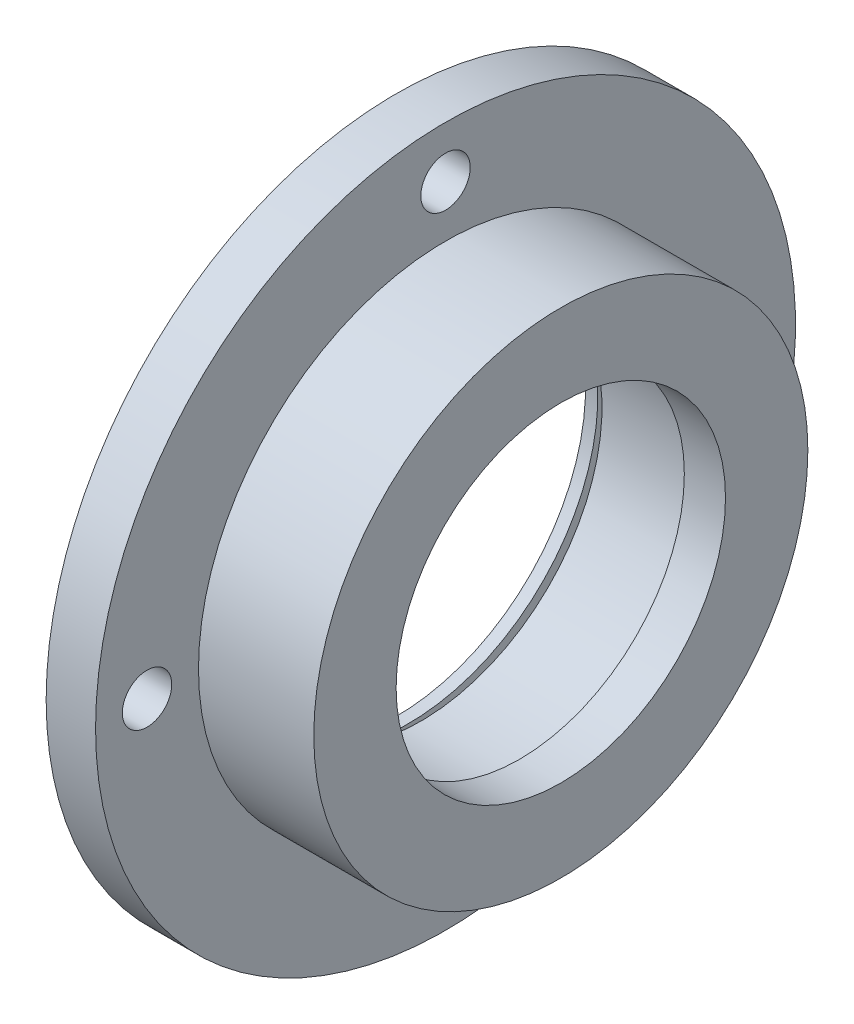
from build123d import *

# Parameters (mm, degrees)
ESBO_O2_R             = 3
CORTE_EXTRUS_O1_DEPTH = 7


with BuildPart() as part:
    # Esboço1 → Revolução1 (revolve)
    with BuildSketch(Plane.XY):
        Polygon((0, 23), (0, 42.5), (6, 42.5), (6, 30), (20, 30), (20, 20), (15, 20), (15, 22), (3, 22), (3, 24.5), (1.5, 24.5), (1.5, 23), align=None)
    revolve(axis=Axis((0, 0, 0), (1, 0, 0)))

    # Esboço2 → Corte-extrusão1 (cut, through all)
    with BuildSketch(Plane(origin=(6, 0, 0), x_dir=(0, 0, -1), z_dir=(1, 0, 0))):
        with Locations((0, 36.25)):
            Circle(ESBO_O2_R)
        with Locations((36.25, 0)):
            Circle(ESBO_O2_R)
        with Locations((0, -36.25)):
            Circle(ESBO_O2_R)
        with Locations((-36.25, 0)):
            Circle(ESBO_O2_R)
    extrude(amount=-CORTE_EXTRUS_O1_DEPTH, mode=Mode.SUBTRACT)


solid = part.part
